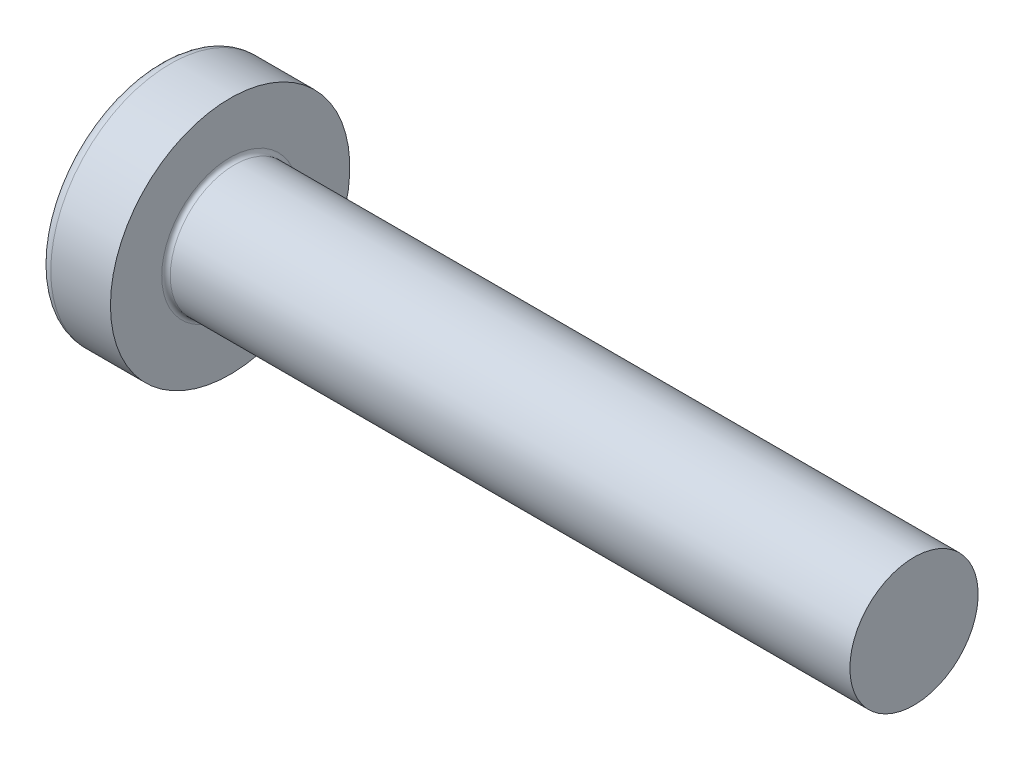
from build123d import *

# Parameters (mm, degrees)
FILLET1_R    = 0.1
SKETCH3_W    = 0.74
SKETCH3_H    = 2.8
SKETCH4_W    = 0.74
SKETCH4_H    = 1.054964664
RECPAT_COUNT = 2
RECPAT_ANGLE = 90


with BuildPart() as part:
    # BodySke → Base-Revolve (revolve)
    with BuildSketch(Plane.XY):
        with BuildLine():
            Line((2.4, 1.5), (2.4, 2.8))
            Line((2.4, 2.8), (1.003501533, 2.8))
            ThreePointArc((1.003501533, 2.8), (0.873295971, 2.76653015), (0.775371599, 2.674418605))
            ThreePointArc((0.775371599, 2.674418605), (0.197753546, 1.392274756), (0, 0))
            Line((0, 0), (18.4, 0))
            Line((18.4, 0), (18.4, 1.5))
            Line((18.4, 1.5), (2.4, 1.5))
        make_face()
    revolve(axis=Axis((-25.4, 0, 0), (1, 0, 0)))

    # Fillet1
    fillet1_edges = [part.edges().sort_by_distance(p)[0] for p in [
        (2.4, -1.5, 0),
    ]]
    fillet(fillet1_edges, radius=FILLET1_R)

    # Sketch3 → Recess section 0
    with BuildSketch(Plane(origin=(0, 0, 0), x_dir=(0, 0, -1), z_dir=(1, 0, 0))):
        Rectangle(SKETCH3_W, SKETCH3_H)
    # Sketch4 → Recess section 1
    with BuildSketch(Plane(origin=(1.75, 0, 0), x_dir=(0, 0, -1), z_dir=(1, 0, 0))):
        Rectangle(SKETCH4_W, SKETCH4_H)
    recess = loft(mode=Mode.SUBTRACT)

    # RecPat: Recess ×2 about axis
    recpat_axis = Axis((0, 0, 0), (1, 0, 0))
    for i in range(1, RECPAT_COUNT):
        add(recess.rotate(recpat_axis, i * RECPAT_ANGLE / (RECPAT_COUNT - 1)), mode=Mode.SUBTRACT)

    # RecCorSke → RecessCore (revolve, cut)
    with BuildSketch(Plane.XY):
        Polygon((0, 0), (0, 0.678371921), (1.75, 0.556), (1.930655351, 0), align=None)
    revolve(axis=Axis((-3.175, 0, 0), (1, 0, 0)), mode=Mode.SUBTRACT)


solid = part.part
